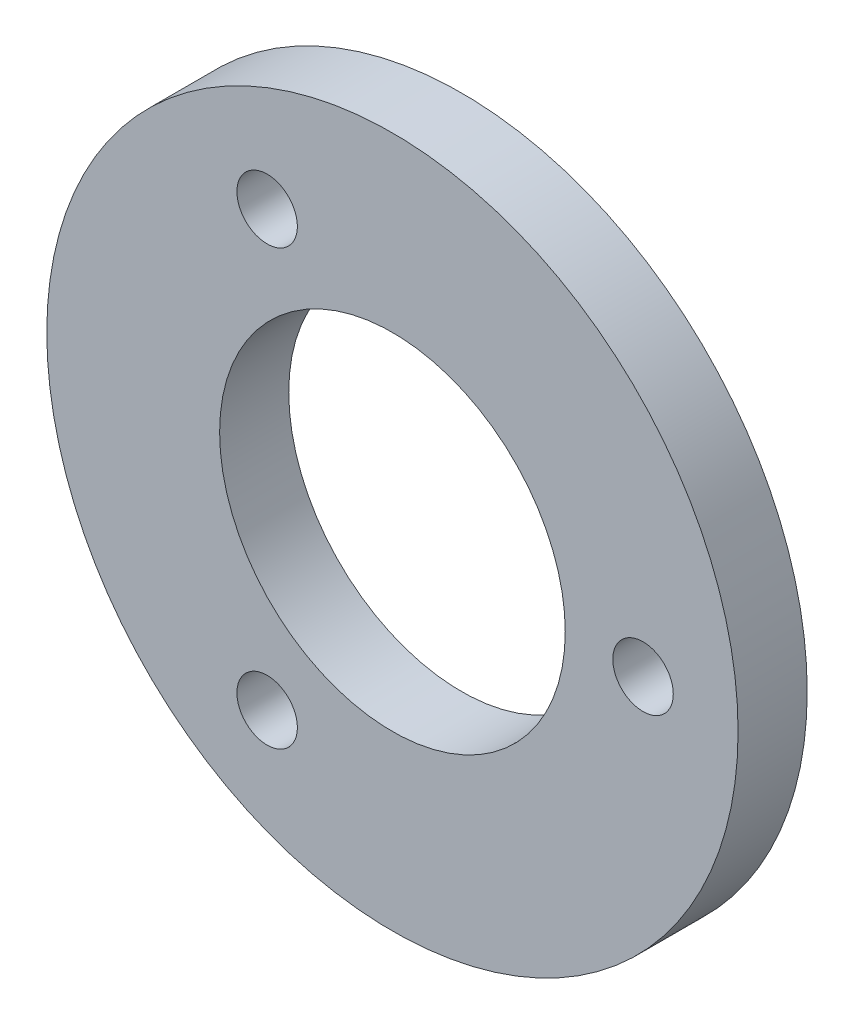
from build123d import *

# Parameters (mm, degrees)
SKETCH1_R           = 20
SKETCH1_R_2         = 10
SKETCH1_R_3         = 1.75
BOSS_EXTRUDE1_DEPTH = 4


with BuildPart() as part:
    # Sketch1 → Boss-Extrude1 (new body)
    with BuildSketch(Plane.XY):
        Circle(SKETCH1_R)
        Circle(SKETCH1_R_2, mode=Mode.SUBTRACT)
        with Locations((14.5, 0)):
            Circle(SKETCH1_R_3, mode=Mode.SUBTRACT)
        with Locations((-7.25, -12.557368355)):
            Circle(SKETCH1_R_3, mode=Mode.SUBTRACT)
        with Locations((-7.25, 12.557368355)):
            Circle(SKETCH1_R_3, mode=Mode.SUBTRACT)
    extrude(amount=BOSS_EXTRUDE1_DEPTH)


solid = part.part
